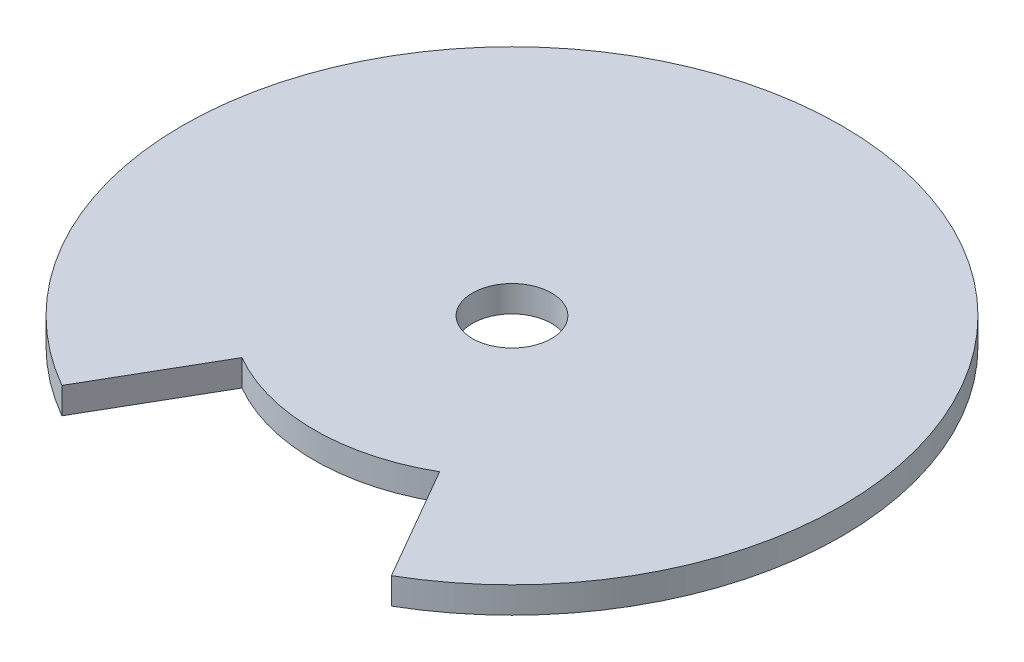
from build123d import *

# Parameters (mm, degrees)
SKETCH_1_R      = 3
EXTRUDE_1_DEPTH = 2


with BuildPart() as part:
    # Эскиз1 → Бобышка-Вытянуть1 (new body)
    with BuildSketch(Plane(origin=(0, 0, 0), x_dir=(1, 0, 0), z_dir=(0, 1, 0))):
        with BuildLine():
            ThreePointArc((-7.5, -12.990381057), (0, -15), (7.5, -12.990381057))
            Line((7.5, -12.990381057), (12.5, -21.650635095))
            ThreePointArc((12.5, -21.650635095), (0, 25), (-12.5, -21.650635095))
            Line((-12.5, -21.650635095), (-7.5, -12.990381057))
        make_face()
        Circle(SKETCH_1_R, mode=Mode.SUBTRACT)
    extrude(amount=EXTRUDE_1_DEPTH)


solid = part.part
